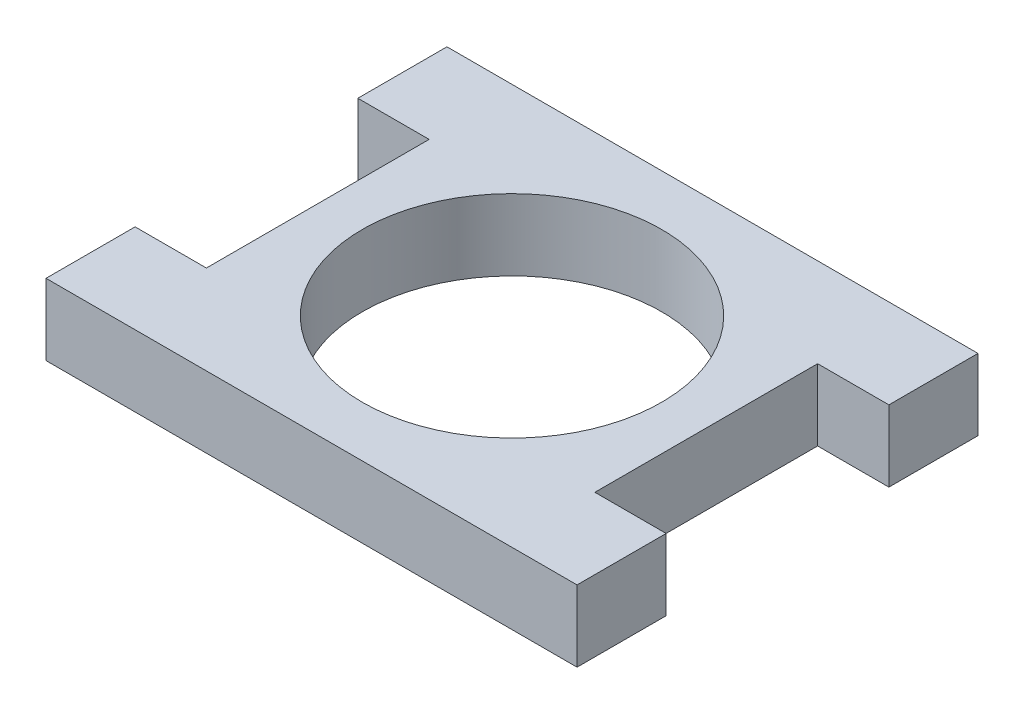
from build123d import *

# Parameters (mm, degrees)
SKETCH1_W           = 5.08
SKETCH1_H           = 6.35
SKETCH1_W_2         = 27.686
SKETCH1_H_2         = 28.575
SKETCH1_R           = 10.668
BOSS_EXTRUDE1_DEPTH = 5.08


with BuildPart() as part:
    # Sketch1 → Boss-Extrude1 (new body)
    with BuildSketch(Plane(origin=(0, 0, 0), x_dir=(1, 0, 0), z_dir=(0, 1, 0))):
        with Locations((-16.383, -11.1125)):
            Rectangle(SKETCH1_W, SKETCH1_H)
        with Locations((-16.383, 11.1125)):
            Rectangle(SKETCH1_W, SKETCH1_H)
        Rectangle(SKETCH1_W_2, SKETCH1_H_2)
        Circle(SKETCH1_R, mode=Mode.SUBTRACT)
        with Locations((16.383, 11.1125)):
            Rectangle(SKETCH1_W, SKETCH1_H)
        with Locations((16.383, -11.1125)):
            Rectangle(SKETCH1_W, SKETCH1_H)
    extrude(amount=BOSS_EXTRUDE1_DEPTH)


solid = part.part
